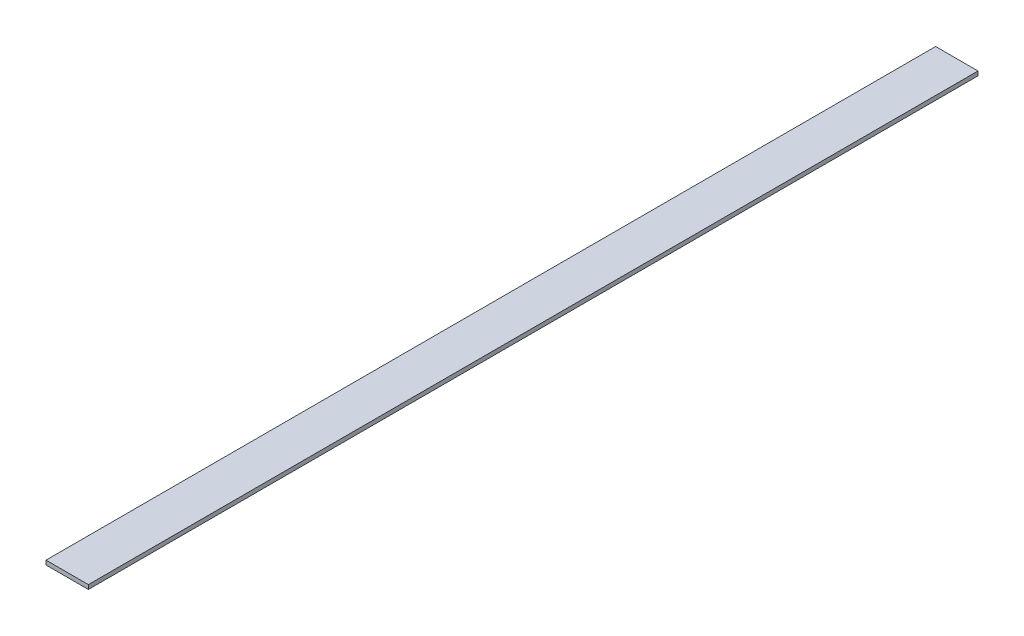
from build123d import *

# Parameters (mm, degrees)
SKETCH1_W           = 50.8
SKETCH1_H           = 1066.8
BOSS_EXTRUDE1_DEPTH = 5.08


with BuildPart() as part:
    # Sketch1 → Boss-Extrude1 (new body)
    with BuildSketch(Plane(origin=(0, 0, 0), x_dir=(1, 0, 0), z_dir=(0, 1, 0))):
        with Locations((-25.4, 533.4)):
            Rectangle(SKETCH1_W, SKETCH1_H)
    extrude(amount=BOSS_EXTRUDE1_DEPTH)


solid = part.part
